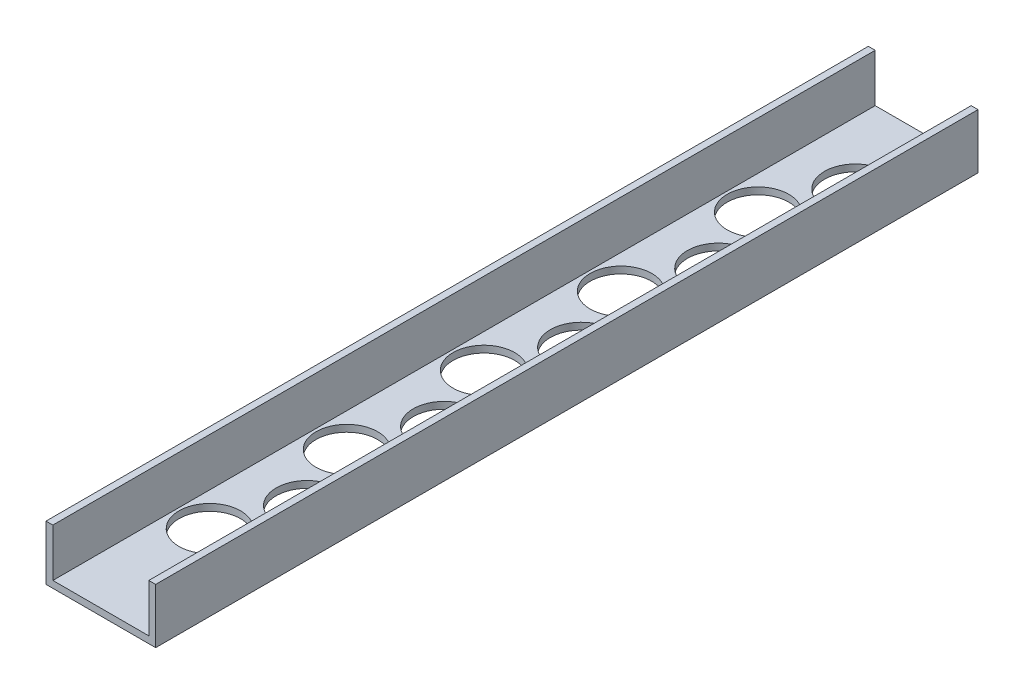
from build123d import *

# Parameters (mm, degrees)
BOSS_EXTRUDE1_DEPTH = 381
CUT_EXTRUDE1_REACH  = 5.175
SKETCH2_R           = 14.2875


with BuildPart() as part:
    # Sketch1 → Boss-Extrude1 (new body)
    with BuildSketch(Plane.XY):
        Polygon((3.175, 3.175), (3.175, 25.4), (0, 25.4), (0, 0), (50.8, 0), (50.8, 25.4), (47.625, 25.4), (47.625, 3.175), align=None)
    extrude(amount=BOSS_EXTRUDE1_DEPTH)

    # Sketch2 → Cut-Extrude1 (cut, up to next)
    with BuildSketch(Plane(origin=(0, 3.175, 0), x_dir=(1, 0, 0), z_dir=(0, 1, 0)), mode=Mode.PRIVATE) as cut_extrude1_sk1:
        with Locations((32.0675, -38.1)):
            Circle(SKETCH2_R)
    cut_extrude1_tool1 = extrude(cut_extrude1_sk1.sketch, amount=-CUT_EXTRUDE1_REACH, mode=Mode.PRIVATE) & part.part
    add(cut_extrude1_tool1.solids().sort_by_distance((32.0675, 3.175, 38.1))[0], mode=Mode.SUBTRACT)
    # Sketch2 → Cut-Extrude1 (cut, up to next)
    with BuildSketch(Plane(origin=(0, 3.175, 0), x_dir=(1, 0, 0), z_dir=(0, 1, 0)), mode=Mode.PRIVATE) as cut_extrude1_sk2:
        with Locations((18.7325, -69.85)):
            Circle(SKETCH2_R)
    cut_extrude1_tool2 = extrude(cut_extrude1_sk2.sketch, amount=-CUT_EXTRUDE1_REACH, mode=Mode.PRIVATE) & part.part
    add(cut_extrude1_tool2.solids().sort_by_distance((18.7325, 3.175, 69.85))[0], mode=Mode.SUBTRACT)
    # Sketch2 → Cut-Extrude1 (cut, up to next)
    with BuildSketch(Plane(origin=(0, 3.175, 0), x_dir=(1, 0, 0), z_dir=(0, 1, 0)), mode=Mode.PRIVATE) as cut_extrude1_sk3:
        with Locations((18.7325, -133.35)):
            Circle(SKETCH2_R)
    cut_extrude1_tool3 = extrude(cut_extrude1_sk3.sketch, amount=-CUT_EXTRUDE1_REACH, mode=Mode.PRIVATE) & part.part
    add(cut_extrude1_tool3.solids().sort_by_distance((18.7325, 3.175, 133.35))[0], mode=Mode.SUBTRACT)
    # Sketch2 → Cut-Extrude1 (cut, up to next)
    with BuildSketch(Plane(origin=(0, 3.175, 0), x_dir=(1, 0, 0), z_dir=(0, 1, 0)), mode=Mode.PRIVATE) as cut_extrude1_sk4:
        with Locations((32.0675, -101.6)):
            Circle(SKETCH2_R)
    cut_extrude1_tool4 = extrude(cut_extrude1_sk4.sketch, amount=-CUT_EXTRUDE1_REACH, mode=Mode.PRIVATE) & part.part
    add(cut_extrude1_tool4.solids().sort_by_distance((32.0675, 3.175, 101.6))[0], mode=Mode.SUBTRACT)
    # Sketch2 → Cut-Extrude1 (cut, up to next)
    with BuildSketch(Plane(origin=(0, 3.175, 0), x_dir=(1, 0, 0), z_dir=(0, 1, 0)), mode=Mode.PRIVATE) as cut_extrude1_sk5:
        with Locations((18.7325, -196.85)):
            Circle(SKETCH2_R)
    cut_extrude1_tool5 = extrude(cut_extrude1_sk5.sketch, amount=-CUT_EXTRUDE1_REACH, mode=Mode.PRIVATE) & part.part
    add(cut_extrude1_tool5.solids().sort_by_distance((18.7325, 3.175, 196.85))[0], mode=Mode.SUBTRACT)
    # Sketch2 → Cut-Extrude1 (cut, up to next)
    with BuildSketch(Plane(origin=(0, 3.175, 0), x_dir=(1, 0, 0), z_dir=(0, 1, 0)), mode=Mode.PRIVATE) as cut_extrude1_sk6:
        with Locations((32.0675, -165.1)):
            Circle(SKETCH2_R)
    cut_extrude1_tool6 = extrude(cut_extrude1_sk6.sketch, amount=-CUT_EXTRUDE1_REACH, mode=Mode.PRIVATE) & part.part
    add(cut_extrude1_tool6.solids().sort_by_distance((32.0675, 3.175, 165.1))[0], mode=Mode.SUBTRACT)
    # Sketch2 → Cut-Extrude1 (cut, up to next)
    with BuildSketch(Plane(origin=(0, 3.175, 0), x_dir=(1, 0, 0), z_dir=(0, 1, 0)), mode=Mode.PRIVATE) as cut_extrude1_sk7:
        with Locations((18.7325, -260.35)):
            Circle(SKETCH2_R)
    cut_extrude1_tool7 = extrude(cut_extrude1_sk7.sketch, amount=-CUT_EXTRUDE1_REACH, mode=Mode.PRIVATE) & part.part
    add(cut_extrude1_tool7.solids().sort_by_distance((18.7325, 3.175, 260.35))[0], mode=Mode.SUBTRACT)
    # Sketch2 → Cut-Extrude1 (cut, up to next)
    with BuildSketch(Plane(origin=(0, 3.175, 0), x_dir=(1, 0, 0), z_dir=(0, 1, 0)), mode=Mode.PRIVATE) as cut_extrude1_sk8:
        with Locations((32.0675, -228.6)):
            Circle(SKETCH2_R)
    cut_extrude1_tool8 = extrude(cut_extrude1_sk8.sketch, amount=-CUT_EXTRUDE1_REACH, mode=Mode.PRIVATE) & part.part
    add(cut_extrude1_tool8.solids().sort_by_distance((32.0675, 3.175, 228.6))[0], mode=Mode.SUBTRACT)
    # Sketch2 → Cut-Extrude1 (cut, up to next)
    with BuildSketch(Plane(origin=(0, 3.175, 0), x_dir=(1, 0, 0), z_dir=(0, 1, 0)), mode=Mode.PRIVATE) as cut_extrude1_sk9:
        with Locations((18.7325, -323.85)):
            Circle(SKETCH2_R)
    cut_extrude1_tool9 = extrude(cut_extrude1_sk9.sketch, amount=-CUT_EXTRUDE1_REACH, mode=Mode.PRIVATE) & part.part
    add(cut_extrude1_tool9.solids().sort_by_distance((18.7325, 3.175, 323.85))[0], mode=Mode.SUBTRACT)
    # Sketch2 → Cut-Extrude1 (cut, up to next)
    with BuildSketch(Plane(origin=(0, 3.175, 0), x_dir=(1, 0, 0), z_dir=(0, 1, 0)), mode=Mode.PRIVATE) as cut_extrude1_sk10:
        with Locations((32.0675, -292.1)):
            Circle(SKETCH2_R)
    cut_extrude1_tool10 = extrude(cut_extrude1_sk10.sketch, amount=-CUT_EXTRUDE1_REACH, mode=Mode.PRIVATE) & part.part
    add(cut_extrude1_tool10.solids().sort_by_distance((32.0675, 3.175, 292.1))[0], mode=Mode.SUBTRACT)


solid = part.part
